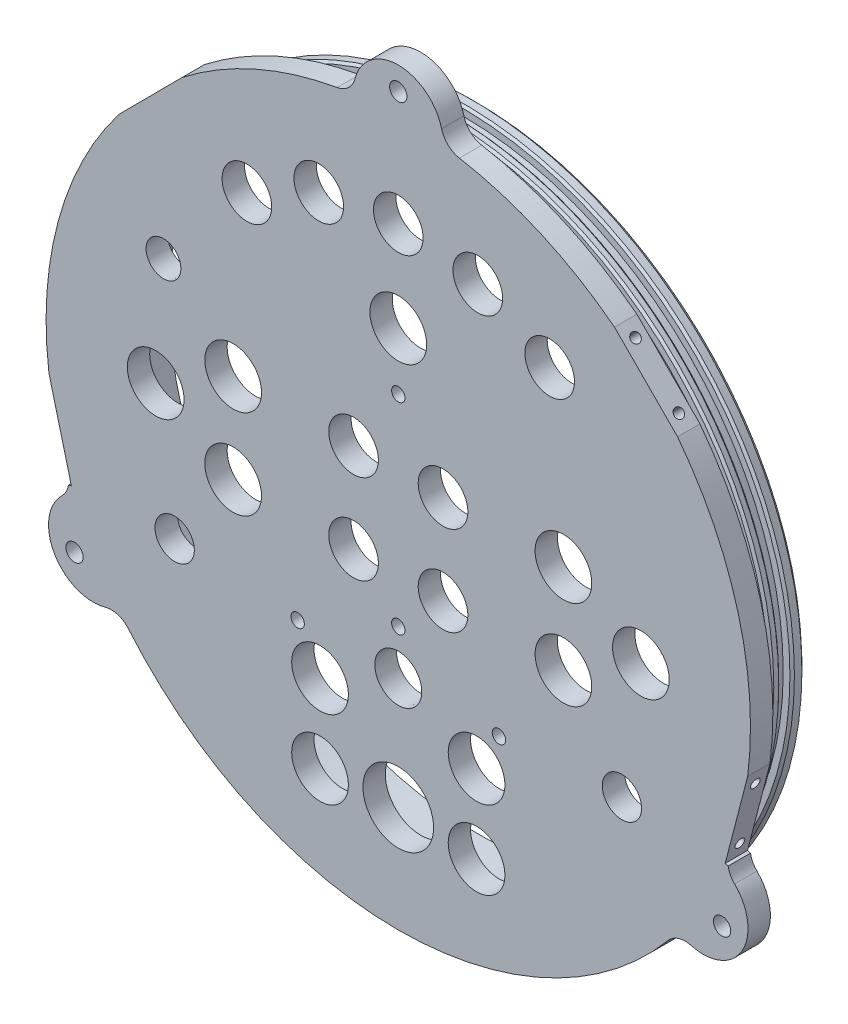
from build123d import *

# Parameters (mm, degrees)
SKETCH1_R                            = 100.0125
EXTRUDE1_DEPTH                       = 6.35
SKETCH2_R                            = 93.6625
EXTRUDE2_DEPTH                       = 15.875
SKETCH3_R                            = 87.3125
CUT_EXTRUDE1_DEPTH                   = 15.875
SKETCH4_W                            = 3.175
SKETCH4_H                            = 2.54
CHAMFER1_SIZE                        = 1.27
EXTRUDE3_DEPTH                       = 6.35
SKETCH5_R                            = 8.05
SKETCH5_R_2                          = 7.050000124
SKETCH5_R_3                          = 5.588
CUT_EXTRUDE2_DEPTH                   = 23.225
F_10_0_1935_DIAMETER_HOLE1_D         = 4.9149
F_10_0_1935_DIAMETER_HOLE1_DEPTH     = 330.2
F_10_0_1935_DIAMETER_HOLE1_TIP       = 1.476584928
CHAMFER2_SIZE                        = 0.635
SKETCH15_R                           = 10.033
CUT_EXTRUDE3_DEPTH                   = 23.225
SKETCH17_R                           = 7.05
SKETCH17_R_2                         = 8.05
CUT_EXTRUDE4_DEPTH                   = 23.225
F_6_CLEARANCE_HOLE1_D                = 3.7973
F_6_CLEARANCE_HOLE1_DEPTH            = 12.7
F_6_CLEARANCE_HOLE1_TIP              = 1.140824014
TAP_DRILL_FOR_6_TAP1_D               = 2.7051
TAP_DRILL_FOR_6_TAP1_DEPTH           = 3.302
TAP_DRILL_FOR_6_TAP1_TIP             = 0.81269403
FILLET1_R                            = 6.35
CUT_EXTRUDE5_DEPTH                   = 23.225
TAP_DRILL_FOR_6_TAP2_D               = 2.7051
TAP_DRILL_FOR_6_TAP2_DEPTH           = 9.525
TAP_DRILL_FOR_6_TAP2_TIP             = 0.81269403
TAP_DRILL_FOR_6_TAP2_ON_FACE_2_D     = 2.7051
TAP_DRILL_FOR_6_TAP2_ON_FACE_2_DEPTH = 9.525
TAP_DRILL_FOR_6_TAP2_ON_FACE_2_TIP   = 0.81269403
TAP_DRILL_FOR_6_TAP2_ON_FACE_3_D     = 2.7051
TAP_DRILL_FOR_6_TAP2_ON_FACE_3_DEPTH = 9.525
TAP_DRILL_FOR_6_TAP2_ON_FACE_3_TIP   = 0.81269403
TAP_DRILL_FOR_6_TAP2_ON_FACE_4_D     = 2.7051
TAP_DRILL_FOR_6_TAP2_ON_FACE_4_DEPTH = 9.525
TAP_DRILL_FOR_6_TAP2_ON_FACE_4_TIP   = 0.81269403
TAP_DRILL_FOR_6_TAP2_ON_FACE_5_D     = 2.7051
TAP_DRILL_FOR_6_TAP2_ON_FACE_5_DEPTH = 9.525
TAP_DRILL_FOR_6_TAP2_ON_FACE_5_TIP   = 0.81269403
TAP_DRILL_FOR_6_TAP2_ON_FACE_6_D     = 2.7051
TAP_DRILL_FOR_6_TAP2_ON_FACE_6_DEPTH = 9.525
TAP_DRILL_FOR_6_TAP2_ON_FACE_6_TIP   = 0.81269403
F_6_CLEARANCE_HOLE2_D                = 3.7973
F_6_CLEARANCE_HOLE2_DEPTH            = 6.35
F_6_CLEARANCE_HOLE2_TIP              = 1.140824014
CUT_EXTRUDE6_DEPTH                   = 7.3500001


with BuildPart() as part:
    # Sketch1 → Extrude1 (new body)
    with BuildSketch(Plane.XY):
        Circle(SKETCH1_R)
    extrude(amount=EXTRUDE1_DEPTH)

    # Sketch2 → Extrude2 (add)
    with BuildSketch(Plane(origin=(0, 0, 0), x_dir=(-1, 0, 0), z_dir=(0, 0, -1))):
        Circle(SKETCH2_R)
    extrude(amount=EXTRUDE2_DEPTH)

    # Sketch3 → Cut-Extrude1 (cut)
    with BuildSketch(Plane(origin=(0, 0, -15.875), x_dir=(-1, 0, 0), z_dir=(0, 0, -1))):
        Circle(SKETCH3_R)
    extrude(amount=-CUT_EXTRUDE1_DEPTH, mode=Mode.SUBTRACT)

    # Sketch4 → Cut-Revolve1 (revolve, cut)
    with BuildSketch(Plane(origin=(0, 0, 0), x_dir=(0, 0, -1), z_dir=(1, 0, 0))):
        with Locations((4.395911794, 92.3925)):
            Rectangle(SKETCH4_W, SKETCH4_H)
        with Locations((10.251990741, 92.3925)):
            Rectangle(SKETCH4_W, SKETCH4_H)
    revolve(axis=Axis((0, 0, 0), (0, 0, -1)), mode=Mode.SUBTRACT)

    # Chamfer1
    chamfer1_edges = [part.edges().sort_by_distance(p)[0] for p in [
        (93.6625, 0, -15.875),
    ]]
    chamfer(chamfer1_edges, length=CHAMFER1_SIZE)

    # Sketch8 → Extrude3 (add)
    with BuildSketch(Plane.XY.offset(6.35)):
        with BuildLine():
            ThreePointArc((-12.674375762, 99.206150794), (0, 112.7125), (12.674375762, 99.206150794))
            ThreePointArc((12.674375762, 99.206150794), (0, 100.0125), (-12.674375762, 99.206150794))
        make_face()
        with BuildLine():
            ThreePointArc((92.25223468, -38.62674401), (97.611888324, -56.35625), (79.577858918, -60.579406784))
            ThreePointArc((79.577858918, -60.579406784), (86.613365696, -50.00625), (92.25223468, -38.62674401))
        make_face()
        with BuildLine():
            ThreePointArc((-92.25223468, -38.62674401), (-97.611888324, -56.35625), (-79.577858918, -60.579406784))
            ThreePointArc((-79.577858918, -60.579406784), (-86.613365696, -50.00625), (-92.25223468, -38.62674401))
        make_face()
    extrude(amount=-EXTRUDE3_DEPTH)

    # Sketch5 → Cut-Extrude2 (cut, through all)
    with BuildSketch(Plane.XY.offset(6.35)):
        with Locations((0, 47.957267442)):
            Circle(SKETCH5_R)
        with Locations((0, 73.66)):
            Circle(SKETCH5_R_2)
        with Locations((-63.5, -35.56)):
            Circle(SKETCH5_R_3)
        with Locations((63.5, -35.56)):
            Circle(SKETCH5_R_3)
    extrude(amount=-CUT_EXTRUDE2_DEPTH, mode=Mode.SUBTRACT)

    # #10 (0.1935) Diameter Hole1
    with Locations(Plane(origin=(0, 106.172778556, 6.35), x_dir=(1, 0, 0), z_dir=(0, 0, 1))):
        with Locations((0, 0), (91.94832342, -159.259167834), (-91.94832342, -159.259167834)):
            Hole(F_10_0_1935_DIAMETER_HOLE1_D / 2, depth=F_10_0_1935_DIAMETER_HOLE1_DEPTH)
            with Locations((0, 0, -(F_10_0_1935_DIAMETER_HOLE1_DEPTH + F_10_0_1935_DIAMETER_HOLE1_TIP / 2))):  # 118° drill point
                Cone(0, F_10_0_1935_DIAMETER_HOLE1_D / 2, F_10_0_1935_DIAMETER_HOLE1_TIP, mode=Mode.SUBTRACT)

    # Chamfer2
    chamfer2_edges = [part.edges().sort_by_distance(p)[0] for p in [
        (93.6625, 0, -2.808411794),
        (93.6625, 0, -5.983411794),
        (93.6625, 0, -8.664490741),
        (93.6625, 0, -11.839490741),
    ]]
    chamfer(chamfer2_edges, length=CHAMFER2_SIZE)

    # Sketch15 → Cut-Extrude3 (cut, through all)
    with BuildSketch(Plane.XY.offset(6.35)):
        with Locations((0, -69.85)):
            Circle(SKETCH15_R)
    extrude(amount=-CUT_EXTRUDE3_DEPTH, mode=Mode.SUBTRACT)

    # Sketch17 → Cut-Extrude4 (cut, through all)
    with BuildSketch(Plane.XY.offset(6.35)):
        with Locations((-22.583106044, 70.112758621)):
            Circle(SKETCH17_R)
        with Locations((-42.9911448, 59.812683177)):
            Circle(SKETCH17_R)
        with Locations((-68.893058109, 0)):
            Circle(SKETCH17_R_2)
        with Locations((-46.896012853, -12.7)):
            Circle(SKETCH17_R_2)
        with Locations((-46.896012853, 12.7)):
            Circle(SKETCH17_R_2)
        with Locations((-12.7, 12.7)):
            Circle(SKETCH17_R)
        with Locations((-12.7, -12.7)):
            Circle(SKETCH17_R)
        with Locations((12.7, -12.7)):
            Circle(SKETCH17_R)
        with Locations((12.7, 12.7)):
            Circle(SKETCH17_R)
        with Locations((46.896012853, 12.7)):
            Circle(SKETCH17_R_2)
        with Locations((46.896012853, -12.7)):
            Circle(SKETCH17_R_2)
        with Locations((68.893058109, 0)):
            Circle(SKETCH17_R_2)
        with Locations((42.9911448, 59.812683177)):
            Circle(SKETCH17_R)
        with Locations((22.583106044, 70.112758621)):
            Circle(SKETCH17_R)
    extrude(amount=-CUT_EXTRUDE4_DEPTH, mode=Mode.SUBTRACT)

    # #6 Clearance Hole1
    with Locations(Plane(origin=(28.575, -38.1, 0), x_dir=(-1, 0, 0), z_dir=(0, 0, -1))):
        with Locations((0, 0), (57.15, 0)):
            Hole(F_6_CLEARANCE_HOLE1_D / 2, depth=F_6_CLEARANCE_HOLE1_DEPTH)
            with Locations((0, 0, -(F_6_CLEARANCE_HOLE1_DEPTH + F_6_CLEARANCE_HOLE1_TIP / 2))):  # 118° drill point
                Cone(0, F_6_CLEARANCE_HOLE1_D / 2, F_6_CLEARANCE_HOLE1_TIP, mode=Mode.SUBTRACT)

    # Tap Drill for #6 Tap1
    with Locations(Plane(origin=(34.925, 29.21, 0), x_dir=(-1, 0, 0), z_dir=(0, 0, -1))):
        with Locations((0, 0), (69.85, 0), (60.325, 0), (9.525, 0), (-9.525, -81.915), (79.375, -81.915)):
            Hole(TAP_DRILL_FOR_6_TAP1_D / 2, depth=TAP_DRILL_FOR_6_TAP1_DEPTH)
            with Locations((0, 0, -(TAP_DRILL_FOR_6_TAP1_DEPTH + TAP_DRILL_FOR_6_TAP1_TIP / 2))):  # 118° drill point
                Cone(0, TAP_DRILL_FOR_6_TAP1_D / 2, TAP_DRILL_FOR_6_TAP1_TIP, mode=Mode.SUBTRACT)

    # Sketch20 → 1/4 NPT Tapped Hole1 (revolve, cut)
    with BuildSketch(Plane(origin=(0, -38.1, 0), x_dir=(0, 1, 0), z_dir=(1, 0, 0))):
        Polygon((0, 0), (0, 20.360347279), (5.5626, 17.018), (5.5626, 9.906), (6.557984794, 9.906), (6.8545837, 0), align=None)
    revolve(axis=Axis((0, -38.1, -6.35), (0, 0, 1)), mode=Mode.SUBTRACT)

    # Sketch16 → 1/8 NPT Tapped Hole1 (revolve, cut)
    with BuildSketch(Plane(origin=(-66.675, 31.75, 0), x_dir=(0, 1, 0), z_dir=(1, 0, 0))):
        Polygon((0, 0), (0, 13.709468714), (4.2164, 11.176), (4.2164, 6.35), (4.936189396, 6.35), (5.1263169, 0), align=None)
    revolve(axis=Axis((-66.675, 31.75, -6.35), (0, 0, 1)), mode=Mode.SUBTRACT)

    # Fillet1
    fillet1_edges = [part.edges().sort_by_distance(p)[0] for p in [
        (12.674375762, 99.206150794, 3.175),
        (-12.674375762, 99.206150794, 3.175),
        (79.577858918, -60.579406784, 3.175),
        (92.25223468, -38.62674401, 3.175),
        (-92.25223468, -38.62674401, 3.175),
        (-79.577858918, -60.579406784, 3.175),
    ]]
    fillet(fillet1_edges, radius=FILLET1_R)

    # Sketch22 → Cut-Extrude5 (cut, through all)
    with BuildSketch(Plane.XY.offset(6.35)):
        Polygon((-79.302036552, 60.940029168), (-70.34752173, 69.945953012), (-61.393006907, 78.951876857), (-66.822744797, 84.350619868), (-84.731774442, 66.338772179), align=None)
        Polygon((-99.212091023, -12.627792806), (-96.021750906, -24.92054392), (-92.831410789, -37.213295033), (-99.212091023, -38.869274231), (-105.592771257, -14.283772004), align=None)
        Polygon((105.592771257, -14.283772004), (99.212091023, -12.627792806), (96.021750906, -24.92054392), (92.831410789, -37.213295033), (99.212091023, -38.869274231), align=None)
        Polygon((84.731774442, 66.338772179), (66.822744797, 84.350619868), (61.393006907, 78.951876857), (70.34752173, 69.945953012), (79.302036552, 60.940029168), align=None)
    extrude(amount=-CUT_EXTRUDE5_DEPTH, mode=Mode.SUBTRACT)

    # Tap Drill for #6 Tap2
    with Locations(Plane(origin=(-93.828392075, -33.37181031, 3.175), x_dir=(0.251207883, -0.967933159, 0), z_dir=(-0.967933159, -0.251207883, 0))):
        with Locations((0, 0)):
            Hole(TAP_DRILL_FOR_6_TAP2_D / 2, depth=TAP_DRILL_FOR_6_TAP2_DEPTH)
            with Locations((0, 0, -(TAP_DRILL_FOR_6_TAP2_DEPTH + TAP_DRILL_FOR_6_TAP2_TIP / 2))):  # 118° drill point
                Cone(0, TAP_DRILL_FOR_6_TAP2_D / 2, TAP_DRILL_FOR_6_TAP2_TIP, mode=Mode.SUBTRACT)

    # Tap Drill for #6 Tap2 on face 2
    with Locations(Plane(origin=(-98.215109736, -16.469277529, 3.175), x_dir=(0.251208031, -0.96793312, 0), z_dir=(-0.96793312, -0.251208031, 0))):
        with Locations((0, 0)):
            Hole(TAP_DRILL_FOR_6_TAP2_ON_FACE_2_D / 2, depth=TAP_DRILL_FOR_6_TAP2_ON_FACE_2_DEPTH)
            with Locations((0, 0, -(TAP_DRILL_FOR_6_TAP2_ON_FACE_2_DEPTH + TAP_DRILL_FOR_6_TAP2_ON_FACE_2_TIP / 2))):  # 118° drill point
                Cone(0, TAP_DRILL_FOR_6_TAP2_ON_FACE_2_D / 2, TAP_DRILL_FOR_6_TAP2_ON_FACE_2_TIP, mode=Mode.SUBTRACT)

    # Tap Drill for #6 Tap2 on face 3
    with Locations(Plane(origin=(-76.50375067, 63.754380369, 3.175), x_dir=(-0.705079885, -0.709127884, 0), z_dir=(-0.709127884, 0.705079885, 0))):
        with Locations((0, 0), (-17.4625, 0)):
            Hole(TAP_DRILL_FOR_6_TAP2_ON_FACE_3_D / 2, depth=TAP_DRILL_FOR_6_TAP2_ON_FACE_3_DEPTH)
            with Locations((0, 0, -(TAP_DRILL_FOR_6_TAP2_ON_FACE_3_DEPTH + TAP_DRILL_FOR_6_TAP2_ON_FACE_3_TIP / 2))):  # 118° drill point
                Cone(0, TAP_DRILL_FOR_6_TAP2_ON_FACE_3_D / 2, TAP_DRILL_FOR_6_TAP2_ON_FACE_3_TIP, mode=Mode.SUBTRACT)

    # Tap Drill for #6 Tap2 on face 4
    with Locations(Plane(origin=(64.191292789, 76.137525655, 3.175), x_dir=(-0.705079885, 0.709127884, 0), z_dir=(0.709127884, 0.705079885, 0))):
        with Locations((0, 0), (-17.4625, 0)):
            Hole(TAP_DRILL_FOR_6_TAP2_ON_FACE_4_D / 2, depth=TAP_DRILL_FOR_6_TAP2_ON_FACE_4_DEPTH)
            with Locations((0, 0, -(TAP_DRILL_FOR_6_TAP2_ON_FACE_4_DEPTH + TAP_DRILL_FOR_6_TAP2_ON_FACE_4_TIP / 2))):  # 118° drill point
                Cone(0, TAP_DRILL_FOR_6_TAP2_ON_FACE_4_D / 2, TAP_DRILL_FOR_6_TAP2_ON_FACE_4_TIP, mode=Mode.SUBTRACT)

    # Tap Drill for #6 Tap2 on face 5
    with Locations(Plane(origin=(98.215109736, -16.469277529, 3.175), x_dir=(0.251208031, 0.96793312, 0), z_dir=(0.96793312, -0.251208031, 0))):
        with Locations((0, 0)):
            Hole(TAP_DRILL_FOR_6_TAP2_ON_FACE_5_D / 2, depth=TAP_DRILL_FOR_6_TAP2_ON_FACE_5_DEPTH)
            with Locations((0, 0, -(TAP_DRILL_FOR_6_TAP2_ON_FACE_5_DEPTH + TAP_DRILL_FOR_6_TAP2_ON_FACE_5_TIP / 2))):  # 118° drill point
                Cone(0, TAP_DRILL_FOR_6_TAP2_ON_FACE_5_D / 2, TAP_DRILL_FOR_6_TAP2_ON_FACE_5_TIP, mode=Mode.SUBTRACT)

    # Tap Drill for #6 Tap2 on face 6
    with Locations(Plane(origin=(93.828392075, -33.37181031, 3.175), x_dir=(0.251208031, 0.96793312, 0), z_dir=(0.96793312, -0.251208031, 0))):
        with Locations((0, 0)):
            Hole(TAP_DRILL_FOR_6_TAP2_ON_FACE_6_D / 2, depth=TAP_DRILL_FOR_6_TAP2_ON_FACE_6_DEPTH)
            with Locations((0, 0, -(TAP_DRILL_FOR_6_TAP2_ON_FACE_6_DEPTH + TAP_DRILL_FOR_6_TAP2_ON_FACE_6_TIP / 2))):  # 118° drill point
                Cone(0, TAP_DRILL_FOR_6_TAP2_ON_FACE_6_D / 2, TAP_DRILL_FOR_6_TAP2_ON_FACE_6_TIP, mode=Mode.SUBTRACT)

    # #6 Clearance Hole2
    with Locations(Plane.XY.offset(6.35)):
        with Locations((0, 31.75), (0, -25.4)):
            Hole(F_6_CLEARANCE_HOLE2_D / 2, depth=F_6_CLEARANCE_HOLE2_DEPTH)
            with Locations((0, 0, -(F_6_CLEARANCE_HOLE2_DEPTH + F_6_CLEARANCE_HOLE2_TIP / 2))):  # 118° drill point
                Cone(0, F_6_CLEARANCE_HOLE2_D / 2, F_6_CLEARANCE_HOLE2_TIP, mode=Mode.SUBTRACT)

    # Sketch26 → Cut-Extrude6 (cut, through all)
    with BuildSketch(Plane(origin=(0, 0, 0), x_dir=(-1, 0, 0), z_dir=(0, 0, -1))):
        with BuildLine():
            ThreePointArc((-22.225, -57.2625), (-16.532790411, -54.904709589), (-14.175, -49.2125))
            Line((-14.175, -49.2125), (-22.225, -49.2125))
            Line((-22.225, -49.2125), (-22.225, -57.2625))
        make_face()
        with BuildLine():
            Line((-22.225, -49.2125), (-14.175, -49.2125))
            ThreePointArc((-14.175, -49.2125), (-27.917209589, -43.520290411), (-22.225, -57.2625))
            Line((-22.225, -57.2625), (-22.225, -49.2125))
        make_face()
        with BuildLine():
            ThreePointArc((30.275, -49.2125), (22.225, -41.1625), (14.175, -49.2125))
            Line((14.175, -49.2125), (22.225, -49.2125))
            Line((22.225, -49.2125), (22.225, -57.2625))
            ThreePointArc((22.225, -57.2625), (27.917209589, -54.904709589), (30.275, -49.2125))
        make_face()
        with BuildLine():
            Line((22.225, -49.2125), (14.175, -49.2125))
            ThreePointArc((14.175, -49.2125), (16.532790411, -54.904709589), (22.225, -57.2625))
            Line((22.225, -57.2625), (22.225, -49.2125))
        make_face()
        with BuildLine():
            ThreePointArc((30.275, -71.4375), (27.917209589, -65.745290411), (22.225, -63.3875))
            Line((22.225, -63.3875), (22.225, -71.4375))
            Line((22.225, -71.4375), (14.175, -71.4375))
            ThreePointArc((14.175, -71.4375), (22.225, -79.4875), (30.275, -71.4375))
        make_face()
        with BuildLine():
            Line((22.225, -71.4375), (22.225, -63.3875))
            ThreePointArc((22.225, -63.3875), (16.532790411, -65.745290411), (14.175, -71.4375))
            Line((14.175, -71.4375), (22.225, -71.4375))
        make_face()
        with BuildLine():
            ThreePointArc((-14.174999971, -71.4375), (-16.532790391, -65.745290391), (-22.225, -63.387499971))
            Line((-22.225, -63.387499971), (-22.225, -71.4375))
            Line((-22.225, -71.4375), (-14.174999971, -71.4375))
        make_face()
        with BuildLine():
            Line((-22.225, -71.4375), (-22.225, -63.387499971))
            ThreePointArc((-22.225, -63.387499971), (-27.917209609, -77.129709609), (-14.174999971, -71.4375))
            Line((-14.174999971, -71.4375), (-22.225, -71.4375))
        make_face()
    extrude(amount=-CUT_EXTRUDE6_DEPTH, mode=Mode.SUBTRACT)


solid = part.part
